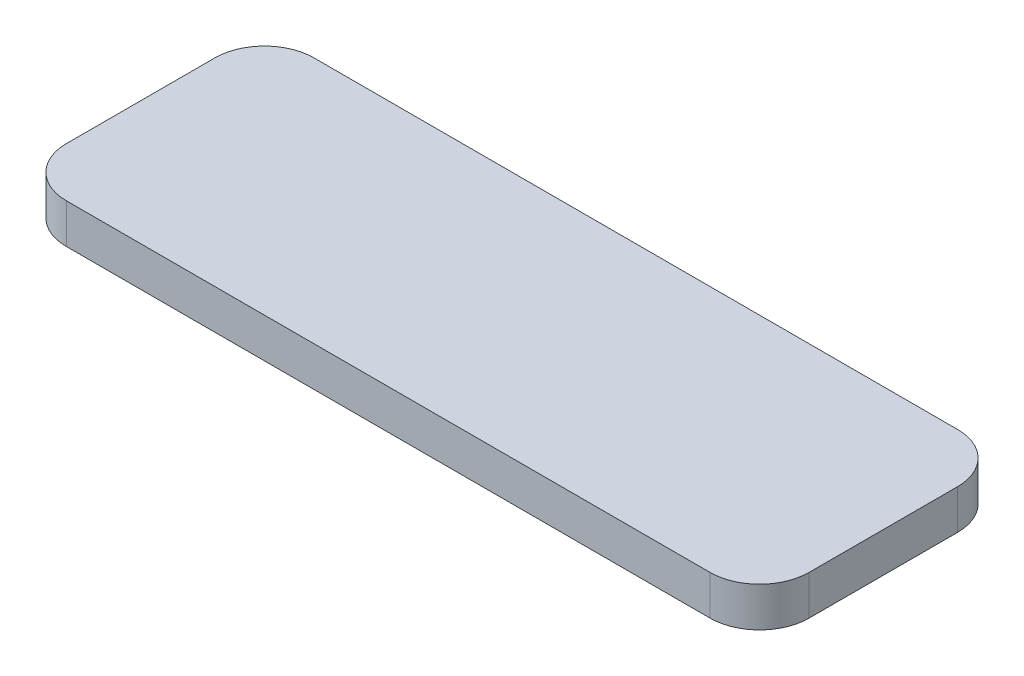
from build123d import *

# Parameters (mm, degrees)
BOSS_EXTRUDE1_DEPTH = 8


with BuildPart() as part:
    # Sketch1 → Boss-Extrude1 (new body)
    with BuildSketch(Plane(origin=(0, 0, 0), x_dir=(1, 0, 0), z_dir=(0, 1, 0))):
        with BuildLine():
            Line((-33.081100963, 49.645781782), (96.918899037, 49.645781782))
            ThreePointArc((96.918899037, 49.645781782), (103.989966849, 46.716849594), (106.918899037, 39.645781782))
            Line((106.918899037, 39.645781782), (106.918899037, 9.645781782))
            ThreePointArc((106.918899037, 9.645781782), (103.989966849, 2.57471397), (96.918899037, -0.354218218))
            Line((96.918899037, -0.354218218), (-33.081100963, -0.354218218))
            ThreePointArc((-33.081100963, -0.354218218), (-40.152168774, 2.57471397), (-43.081100963, 9.645781782))
            Line((-43.081100963, 9.645781782), (-43.081100963, 39.645781782))
            ThreePointArc((-43.081100963, 39.645781782), (-40.152168774, 46.716849594), (-33.081100963, 49.645781782))
        make_face()
    extrude(amount=BOSS_EXTRUDE1_DEPTH)


solid = part.part
